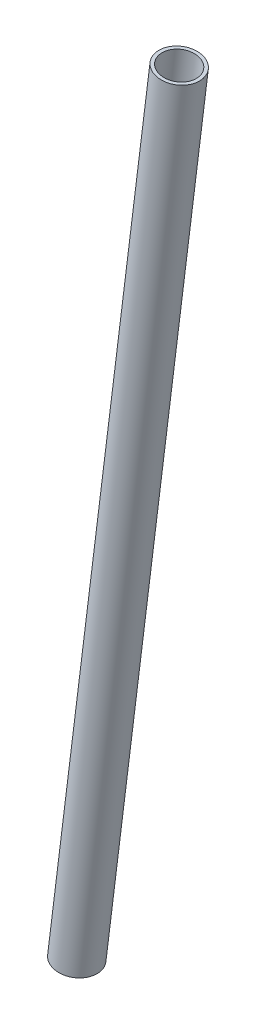
from build123d import *

# Parameters (mm, degrees)
SWEEP_THIN1_PROFILE_R   = 6.35
SWEEP_THIN1_PROFILE_R_2 = 5.35


with BuildPart() as part:
    # Sweep-Thin1: sweep along a curve in space
    with BuildLine() as sweep_thin1_path:
        Line((573.972771974, 224.054469541, 43.85488153), (610.297228026, 481.215530459, 48.84511847))
    # Sweep-Thin1 profile (on start of the path) → Sweep-Thin1 (sweep)
    with BuildSketch(Plane(origin=(573.972771974, 224.054469541, 43.85488153), x_dir=(0.9901708104920794, -0.13986338351927066, 0), z_dir=(0.13983757245237904, 0.9899880795700851, 0.019210820902828444))):
        Circle(SWEEP_THIN1_PROFILE_R)
        Circle(SWEEP_THIN1_PROFILE_R_2, mode=Mode.SUBTRACT)
    sweep(path=sweep_thin1_path.line)


solid = part.part
